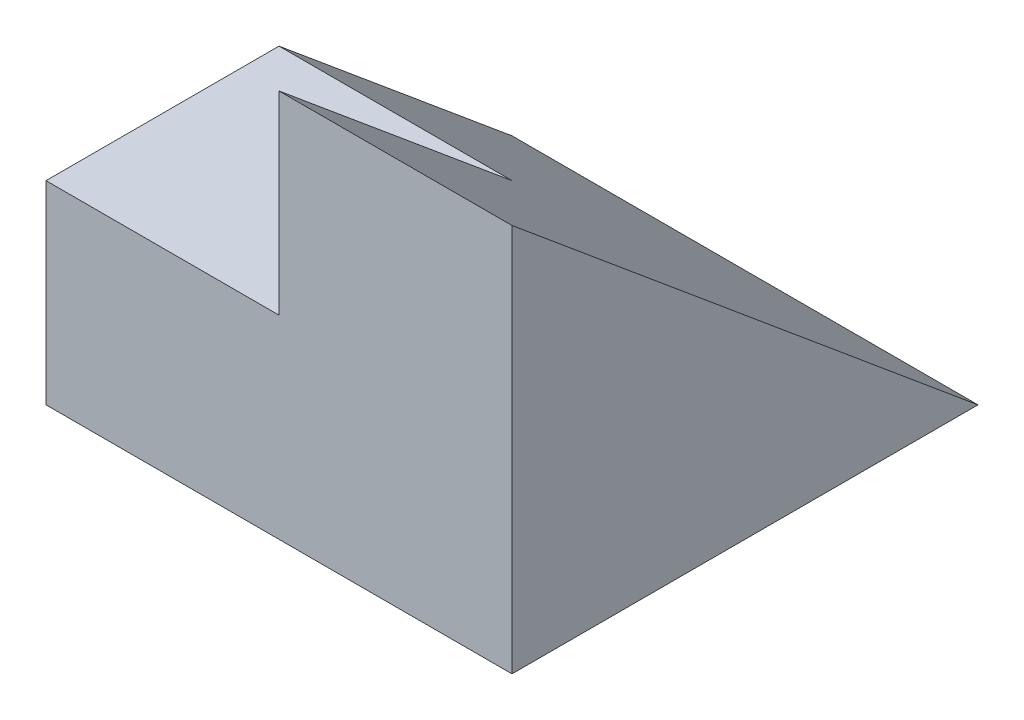
from build123d import *

# Parameters (mm, degrees)
SKETCH1_W           = 6
SKETCH1_H           = 6
BOSS_EXTRUDE1_DEPTH = 5
CUT_EXTRUDE9_DEPTH  = 23.5
CUT_EXTRUDE10_DEPTH = 3


with BuildPart() as part:
    # Sketch1 → Boss-Extrude1 (new body)
    with BuildSketch(Plane(origin=(0, 0, 0), x_dir=(1, 0, 0), z_dir=(0, 1, 0))):
        Rectangle(SKETCH1_W, SKETCH1_H)
    extrude(amount=BOSS_EXTRUDE1_DEPTH)

    # Sketch12 → Cut-Extrude9 (cut)
    with BuildSketch(Plane.ZY.offset(3)):
        Polygon((-3, 0), (3, 5), (-3, 5), align=None)
    extrude(amount=-CUT_EXTRUDE9_DEPTH, mode=Mode.SUBTRACT)

    # Sketch13 → Cut-Extrude10 (cut)
    with BuildSketch(Plane.ZY.offset(3)):
        Polygon((3, 5), (0, 2.5), (3, 2.5), align=None)
    extrude(amount=-CUT_EXTRUDE10_DEPTH, mode=Mode.SUBTRACT)


solid = part.part
